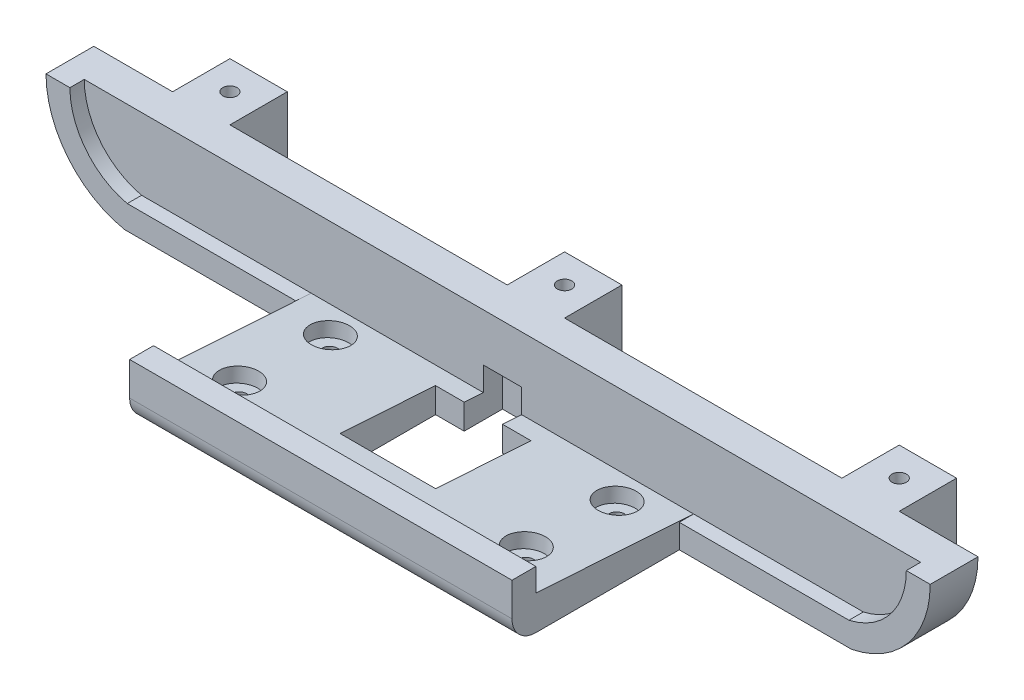
from build123d import *

# Parameters (mm, degrees)
ESTRUSIONE_ESTRUSIONE1_DEPTH  = 10
TAGLIO_ESTRUSIONE1_DEPTH      = 3
SCHIZZO4_W                    = 80
SCHIZZO4_H                    = 5
ESTRUSIONE_ESTRUSIONE2_DEPTH  = 35
ESTRUSIONE_ESTRUSIONE4_DEPTH  = 80
SCHIZZO7_W                    = 80
SCHIZZO7_H                    = 5
ESTRUSIONE_ESTRUSIONE5_DEPTH  = 7
TAGLIO_ESTRUSIONE2_REACH      = 112.369
SCHIZZO8_R                    = 1.5
RACCORDO1_R                   = 5
RACCORDO2_R                   = 5
TAGLIO_ESTRUSIONE3_DEPTH      = 111.368700273
TAGLIO_ESTRUSIONE3_DEPTH_BACK = 10
SCHIZZO11_R                   = 4
TAGLIO_ESTRUSIONE4_DEPTH      = 3
SCHIZZO12_W                   = 12
SCHIZZO12_H                   = 12
ESTRUSIONE_ESTRUSIONE6_DEPTH  = 40
SCHIZZO13_R                   = 1.5
TAGLIO_ESTRUSIONE5_DEPTH      = 111.368700273
SCHIZZO14_R                   = 4
TAGLIO_ESTRUSIONE6_DEPTH      = 10


with BuildPart() as part:
    # Schizzo1 → Estrusione-Estrusione1 (new body)
    with BuildSketch(Plane.XY):
        with BuildLine():
            Line((-76.016095604, 20), (76.016095604, 20))
            ThreePointArc((76.016095604, 20), (92.5, 0), (76.016095604, -20))
            Line((76.016095604, -20), (-76.016095604, -20))
            ThreePointArc((-76.016095604, -20), (-92.5, 0), (-76.016095604, 20))
        make_face()
    extrude(amount=ESTRUSIONE_ESTRUSIONE1_DEPTH)

    # Schizzo3 → Taglio-Estrusione1 (cut)
    with BuildSketch(Plane.XY.offset(10)):
        with BuildLine():
            Line((-75.5, -15), (75.5, -15))
            ThreePointArc((75.5, -15), (87.5, 0), (75.5, 15))
            Line((75.5, 15), (-75.5, 15))
            ThreePointArc((-75.5, 15), (-87.5, 0), (-75.5, -15))
        make_face()
    extrude(amount=-TAGLIO_ESTRUSIONE1_DEPTH, mode=Mode.SUBTRACT)

    # Schizzo4 → Estrusione-Estrusione2 (add)
    with BuildSketch(Plane.XY.offset(10)):
        with Locations((0, -17.5)):
            Rectangle(SCHIZZO4_W, SCHIZZO4_H)
    estrusione_estrusione2 = extrude(amount=ESTRUSIONE_ESTRUSIONE2_DEPTH)

    # Schizzo6 → Estrusione-Estrusione4 (add)
    with BuildSketch(Plane(origin=(40, 0, 0), x_dir=(0, 0, -1), z_dir=(1, 0, 0))):
        Polygon((-40, -15), (-40, -12.81), (-7, -15), align=None)
    estrusione_estrusione4 = extrude(amount=-ESTRUSIONE_ESTRUSIONE4_DEPTH)

    # Schizzo7 → Estrusione-Estrusione5 (add)
    with BuildSketch(Plane(origin=(0, -15, 0), x_dir=(1, 0, 0), z_dir=(0, 1, 0))):
        with Locations((0, -42.5)):
            Rectangle(SCHIZZO7_W, SCHIZZO7_H)
    estrusione_estrusione5 = extrude(amount=ESTRUSIONE_ESTRUSIONE5_DEPTH)

    # Taglio-Estrusione2: up to this plane
    taglio_estrusione2_end = Plane(origin=(-40, -12.81, 40), z_dir=(1.4576135341627736e-15, 0.9978051809344605, -0.0662179801892863))
    # Schizzo8 → Taglio-Estrusione2 (cut, up to the surface)
    with BuildSketch(Plane.XZ.offset(20), mode=Mode.PRIVATE) as taglio_estrusione2_sk1:
        with Locations(Location((-30, 13, 0), (0, 0, 270))):
            Circle(SCHIZZO8_R)
    taglio_estrusione2_tool1 = split(extrude(taglio_estrusione2_sk1.sketch, amount=-TAGLIO_ESTRUSIONE2_REACH, mode=Mode.PRIVATE), bisect_by=taglio_estrusione2_end, keep=Keep.BOTH, mode=Mode.PRIVATE)
    add(taglio_estrusione2_tool1.solids().sort_by_distance((-30, -20, 13))[0], mode=Mode.SUBTRACT)
    # Schizzo8 → Taglio-Estrusione2 (cut, up to the surface)
    with BuildSketch(Plane.XZ.offset(20), mode=Mode.PRIVATE) as taglio_estrusione2_sk2:
        with Locations(Location((-30, 32, 0), (0, 0, 270))):
            Circle(SCHIZZO8_R)
    taglio_estrusione2_tool2 = split(extrude(taglio_estrusione2_sk2.sketch, amount=-TAGLIO_ESTRUSIONE2_REACH, mode=Mode.PRIVATE), bisect_by=taglio_estrusione2_end, keep=Keep.BOTH, mode=Mode.PRIVATE)
    add(taglio_estrusione2_tool2.solids().sort_by_distance((-30, -20, 32))[0], mode=Mode.SUBTRACT)
    # Schizzo8 → Taglio-Estrusione2 (cut, up to the surface)
    with BuildSketch(Plane.XZ.offset(20), mode=Mode.PRIVATE) as taglio_estrusione2_sk3:
        with Locations(Location((30, 13, 0), (0, 0, 270))):
            Circle(SCHIZZO8_R)
    taglio_estrusione2_tool3 = split(extrude(taglio_estrusione2_sk3.sketch, amount=-TAGLIO_ESTRUSIONE2_REACH, mode=Mode.PRIVATE), bisect_by=taglio_estrusione2_end, keep=Keep.BOTH, mode=Mode.PRIVATE)
    add(taglio_estrusione2_tool3.solids().sort_by_distance((30, -20, 13))[0], mode=Mode.SUBTRACT)
    # Schizzo8 → Taglio-Estrusione2 (cut, up to the surface)
    with BuildSketch(Plane.XZ.offset(20), mode=Mode.PRIVATE) as taglio_estrusione2_sk4:
        with Locations(Location((30, 32, 0), (0, 0, 270))):
            Circle(SCHIZZO8_R)
    taglio_estrusione2_tool4 = split(extrude(taglio_estrusione2_sk4.sketch, amount=-TAGLIO_ESTRUSIONE2_REACH, mode=Mode.PRIVATE), bisect_by=taglio_estrusione2_end, keep=Keep.BOTH, mode=Mode.PRIVATE)
    add(taglio_estrusione2_tool4.solids().sort_by_distance((30, -20, 32))[0], mode=Mode.SUBTRACT)

    # Specchia1: Estrusione-Estrusione2, Estrusione-Estrusione4, Estrusione-Estrusione5 across plane
    add(estrusione_estrusione2.mirror(Plane.ZX))
    add(estrusione_estrusione4.mirror(Plane.ZX))
    add(estrusione_estrusione5.mirror(Plane.ZX))

    # Raccordo1
    raccordo1_edges = [part.edges().sort_by_distance(p)[0] for p in [
        (0, -20, 45),
    ]]
    fillet(raccordo1_edges, radius=RACCORDO1_R)

    # Raccordo2
    raccordo2_edges = [part.edges().sort_by_distance(p)[0] for p in [
        (0, 20, 45),
    ]]
    fillet(raccordo2_edges, radius=RACCORDO2_R)

    # Schizzo9 → Taglio-Estrusione3 (cut, two sides)
    with BuildSketch(Plane.XZ.offset(20)) as taglio_estrusione3_sk:
        Polygon((-4, 11), (-4, 3), (4, 3), (4, 11), (10, 11), (10, 31), (-10, 31), (-10, 11), align=None)
    extrude(amount=TAGLIO_ESTRUSIONE3_DEPTH, mode=Mode.SUBTRACT)
    extrude(taglio_estrusione3_sk.sketch, amount=-TAGLIO_ESTRUSIONE3_DEPTH_BACK, mode=Mode.SUBTRACT)

    # Schizzo11 → Taglio-Estrusione4 (cut)
    with BuildSketch(Plane(origin=(0, -15.396736192, 1.021783402), x_dir=(1, 0, 0), z_dir=(1.4576135341627738e-15, 0.9978051809344605, -0.06621798018928632))):
        with Locations(Location((-30, -12.004564445, 0), (0, 0, 270))):
            Circle(SCHIZZO11_R)
        with Locations(Location((-30, -31.046357736, 0), (0, 0, 270))):
            Circle(SCHIZZO11_R)
        with Locations(Location((30, -31.046357736, 0), (0, 0, 270))):
            Circle(SCHIZZO11_R)
        with Locations(Location((30, -12.004564445, 0), (0, 0, 270))):
            Circle(SCHIZZO11_R)
    extrude(amount=-TAGLIO_ESTRUSIONE4_DEPTH, mode=Mode.SUBTRACT)

    # Schizzo12 → Estrusione-Estrusione6 (add)
    with BuildSketch(Plane.XZ.offset(20)):
        with Locations((70.016095604, -6)):
            Rectangle(SCHIZZO12_W, SCHIZZO12_H)
        with Locations((-70.016095604, -6)):
            Rectangle(SCHIZZO12_W, SCHIZZO12_H)
        with Locations((0, -6)):
            Rectangle(SCHIZZO12_W, SCHIZZO12_H)
    extrude(amount=-ESTRUSIONE_ESTRUSIONE6_DEPTH)

    # Schizzo13 → Taglio-Estrusione5 (cut, through all)
    with BuildSketch(Plane.XZ.offset(20)):
        with Locations(Location((-70.016095604, -6, 0), (0, 0, 270))):
            Circle(SCHIZZO13_R)
        with Locations(Location((0, -6, 0), (0, 0, 270))):
            Circle(SCHIZZO13_R)
        with Locations(Location((70.016095604, -6, 0), (0, 0, 270))):
            Circle(SCHIZZO13_R)
    extrude(amount=-TAGLIO_ESTRUSIONE5_DEPTH, mode=Mode.SUBTRACT)

    # Schizzo14 → Taglio-Estrusione6 (cut)
    with BuildSketch(Plane.XZ.offset(20)):
        with Locations(Location((-70.016095604, -6, 0), (0, 0, 270))):
            Circle(SCHIZZO14_R)
        with Locations(Location((0, -6, 0), (0, 0, 270))):
            Circle(SCHIZZO14_R)
        with Locations(Location((70.016095604, -6, 0), (0, 0, 270))):
            Circle(SCHIZZO14_R)
    taglio_estrusione6 = extrude(amount=-TAGLIO_ESTRUSIONE6_DEPTH, mode=Mode.SUBTRACT)

    # Specchia2: Taglio-Estrusione6 across plane
    add(taglio_estrusione6.mirror(Plane.ZX), mode=Mode.SUBTRACT)

    # TaglioSuperficie1
    split(bisect_by=Plane(origin=(0, 0, 0), x_dir=(1, 0, 0), z_dir=(0, 1, 0)), keep=Keep.BOTTOM)


solid = part.part
